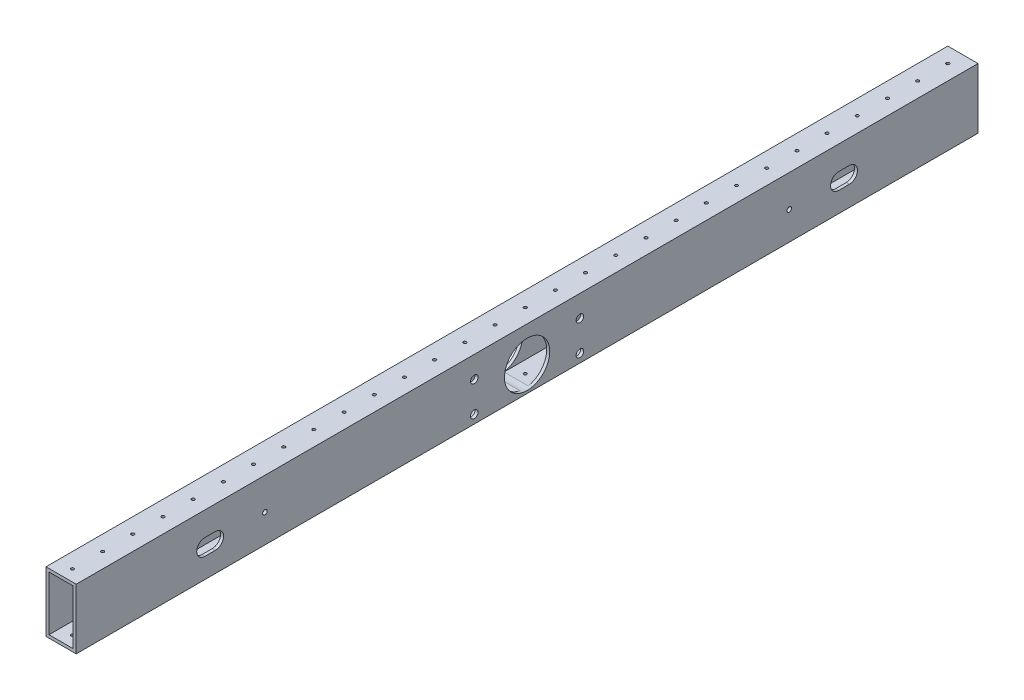
from build123d import *

# Parameters (mm, degrees)
SKETCH1_W           = 25.4
SKETCH1_H           = 50.8
SKETCH1_W_2         = 20.32
SKETCH1_H_2         = 45.72
EXTRUDE_THIN1_DEPTH = 379.4125
SKETCH2_R           = 1.27
CUT_EXTRUDE1_DEPTH  = 51.8
LPATTERN1_COUNT     = 30
LPATTERN1_PITCH     = 25.4
SKETCH4_R           = 19.05
SKETCH4_R_2         = 1.9304
CUT_EXTRUDE2_DEPTH  = 26.4
SKETCH5_R           = 3.175
CUT_EXTRUDE3_DEPTH  = 26.4


with BuildPart() as part:
    # Sketch1 → Extrude-Thin1 (new body, symmetric)
    with BuildSketch(Plane.XY):
        Rectangle(SKETCH1_W, SKETCH1_H)
        Rectangle(SKETCH1_W_2, SKETCH1_H_2, mode=Mode.SUBTRACT)
    extrude(amount=EXTRUDE_THIN1_DEPTH, both=True)

    # Sketch2 → Cut-Extrude1 (cut, through all)
    with BuildSketch(Plane(origin=(0, 25.4, 0), x_dir=(1, 0, 0), z_dir=(0, 1, 0))):
        with Locations((0, 366.7125)):
            Circle(SKETCH2_R)
    cut_extrude1 = extrude(amount=-CUT_EXTRUDE1_DEPTH, mode=Mode.SUBTRACT)

    # LPattern1: Cut-Extrude1 ×30
    with Locations(*[(0, 0, i * LPATTERN1_PITCH) for i in range(1, LPATTERN1_COUNT)]):
        add(cut_extrude1, mode=Mode.SUBTRACT)

    # Sketch4 → Cut-Extrude2 (cut, through all)
    with BuildSketch(Plane.ZY.offset(12.7)):
        with Locations((0, -4.1275)):
            Circle(SKETCH4_R)
        with Locations((-220.586904488, -1.5875)):
            Circle(SKETCH4_R_2)
        with Locations((220.586904488, -1.5875)):
            Circle(SKETCH4_R_2)
        with BuildLine():
            Line((-262.242904488, 5.2705), (-271.132904488, 5.2705))
            ThreePointArc((-271.132904488, 5.2705), (-277.990904488, -1.5875), (-271.132904488, -8.4455))
            Line((-271.132904488, -8.4455), (-262.242904488, -8.4455))
            ThreePointArc((-262.242904488, -8.4455), (-255.384904488, -1.5875), (-262.242904488, 5.2705))
        make_face()
        with BuildLine():
            Line((262.242904488, 5.2705), (271.132904488, 5.2705))
            ThreePointArc((271.132904488, 5.2705), (277.990904488, -1.5875), (271.132904488, -8.4455))
            Line((271.132904488, -8.4455), (262.242904488, -8.4455))
            ThreePointArc((262.242904488, -8.4455), (255.384904488, -1.5875), (262.242904488, 5.2705))
        make_face()
    extrude(amount=-CUT_EXTRUDE2_DEPTH, mode=Mode.SUBTRACT)

    # Sketch5 → Cut-Extrude3 (cut, through all)
    with BuildSketch(Plane.ZY.offset(12.7)):
        with Locations((-44.45, 7.179966082)):
            Circle(SKETCH5_R)
        with Locations((-44.45, -18.220033918)):
            Circle(SKETCH5_R)
        with Locations((44.45, 7.179966082)):
            Circle(SKETCH5_R)
        with Locations((44.45, -18.220033918)):
            Circle(SKETCH5_R)
    extrude(amount=-CUT_EXTRUDE3_DEPTH, mode=Mode.SUBTRACT)


solid = part.part
